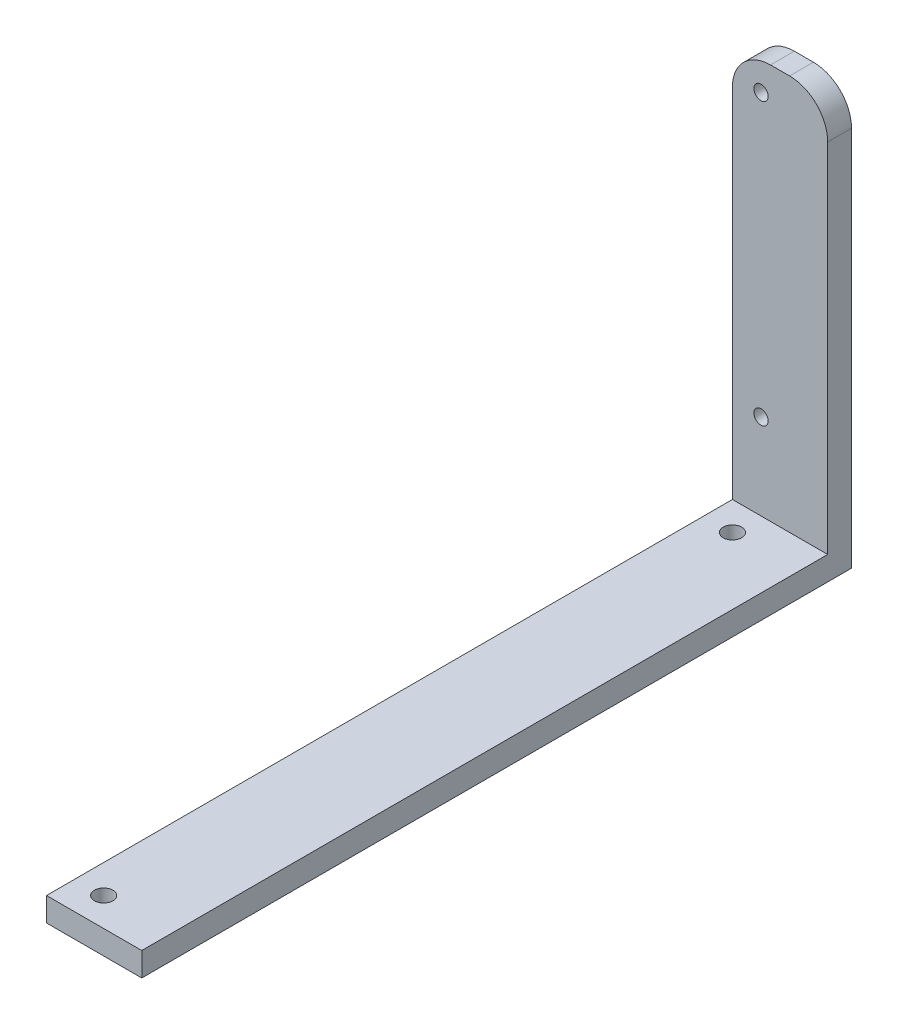
from build123d import *

# Parameters (mm, degrees)
SKETCH1_W           = 20
SKETCH1_H           = 88
SKETCH1_R           = 1.5
BOSS_EXTRUDE1_DEPTH = 5
SKETCH2_W           = 20
SKETCH2_H           = 5
BOSS_EXTRUDE2_DEPTH = 144
FILLET1_R           = 8
SKETCH3_R           = 1.939400698
CUT_EXTRUDE1_DEPTH  = 6


with BuildPart() as part:
    # Sketch1 → Boss-Extrude1 (new body)
    with BuildSketch(Plane.XY):
        with Locations((10, 44)):
            Rectangle(SKETCH1_W, SKETCH1_H)
        with Locations((6, 82)):
            Circle(SKETCH1_R, mode=Mode.SUBTRACT)
        with Locations((6, 23)):
            Circle(SKETCH1_R, mode=Mode.SUBTRACT)
    extrude(amount=BOSS_EXTRUDE1_DEPTH)

    # Sketch2 → Boss-Extrude2 (add)
    with BuildSketch(Plane.XY.offset(5)):
        with Locations((10, 2.5)):
            Rectangle(SKETCH2_W, SKETCH2_H)
    extrude(amount=BOSS_EXTRUDE2_DEPTH)

    # Fillet1
    fillet1_edges = [part.edges().sort_by_distance(p)[0] for p in [
        (20, 88, 2.5),
        (0, 88, 2.5),
    ]]
    fillet(fillet1_edges, radius=FILLET1_R)

    # Sketch3 → Cut-Extrude1 (cut, through all)
    with BuildSketch(Plane(origin=(0, 5, 0), x_dir=(1, 0, 0), z_dir=(0, 1, 0))):
        with Locations((6, -143)):
            Circle(SKETCH3_R)
        with Locations((6, -11)):
            Circle(SKETCH3_R)
    extrude(amount=-CUT_EXTRUDE1_DEPTH, mode=Mode.SUBTRACT)


solid = part.part
